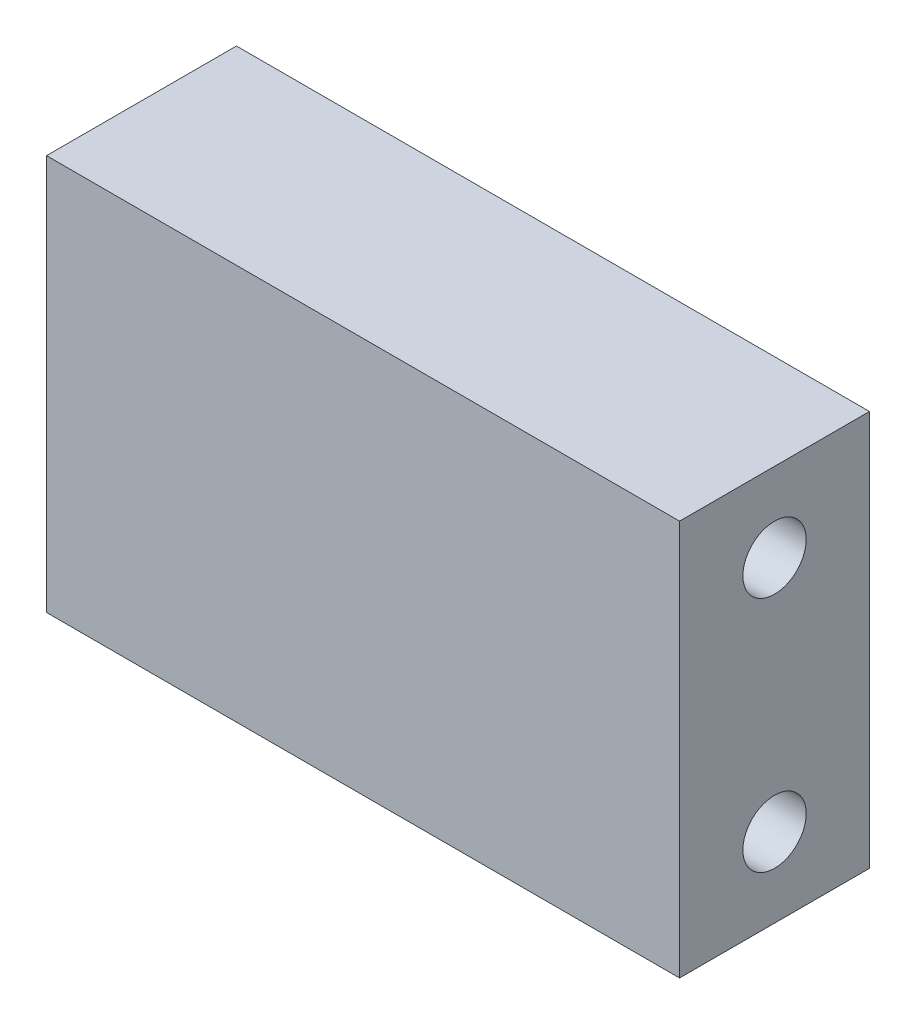
from build123d import *

# Parameters (mm, degrees)
ESQUISSE1_W                       = 40
ESQUISSE1_H                       = 25
BOSS_EXTRU_1_DEPTH                = 12
DIAM_TRE_DU_PER_AGE_4_0_4_1_D     = 4
DIAM_TRE_DU_PER_AGE_4_0_4_1_DEPTH = 40


with BuildPart() as part:
    # Esquisse1 → Boss.-Extru.1 (new body)
    with BuildSketch(Plane.XY):
        with Locations((20, 12.5)):
            Rectangle(ESQUISSE1_W, ESQUISSE1_H)
    extrude(amount=BOSS_EXTRU_1_DEPTH)

    # Diamètre du perçage Ø4.0 (4)1
    with Locations(Plane(origin=(40, 0, 0), x_dir=(0, 0, -1), z_dir=(1, 0, 0))):
        with Locations((-6, 20), (-6, 5)):
            Hole(DIAM_TRE_DU_PER_AGE_4_0_4_1_D / 2, depth=DIAM_TRE_DU_PER_AGE_4_0_4_1_DEPTH)


solid = part.part
